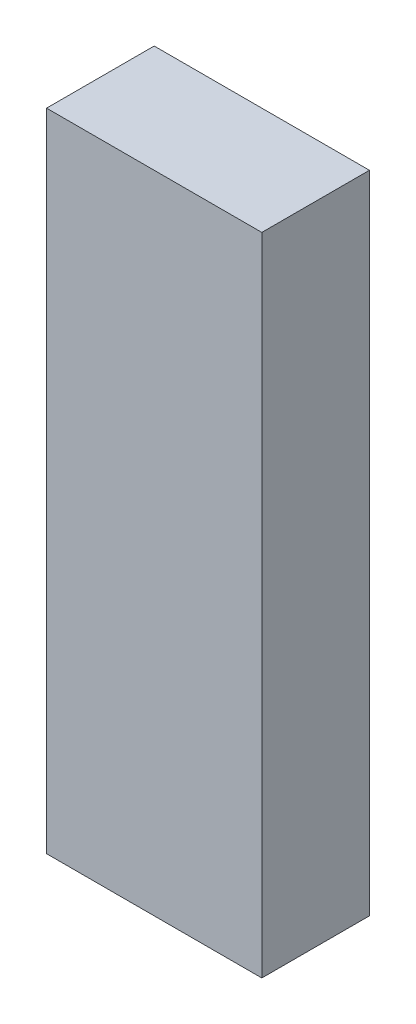
from build123d import *

# Parameters (mm, degrees)
ESQUISSE1_W        = 10
ESQUISSE1_H        = 30
BOSS_EXTRU_1_DEPTH = 5


with BuildPart() as part:
    # Esquisse1 → Boss.-Extru.1 (new body)
    with BuildSketch(Plane.XY):
        with Locations((-59.097367664, -10.592424242)):
            Rectangle(ESQUISSE1_W, ESQUISSE1_H)
    extrude(amount=BOSS_EXTRU_1_DEPTH)


solid = part.part
